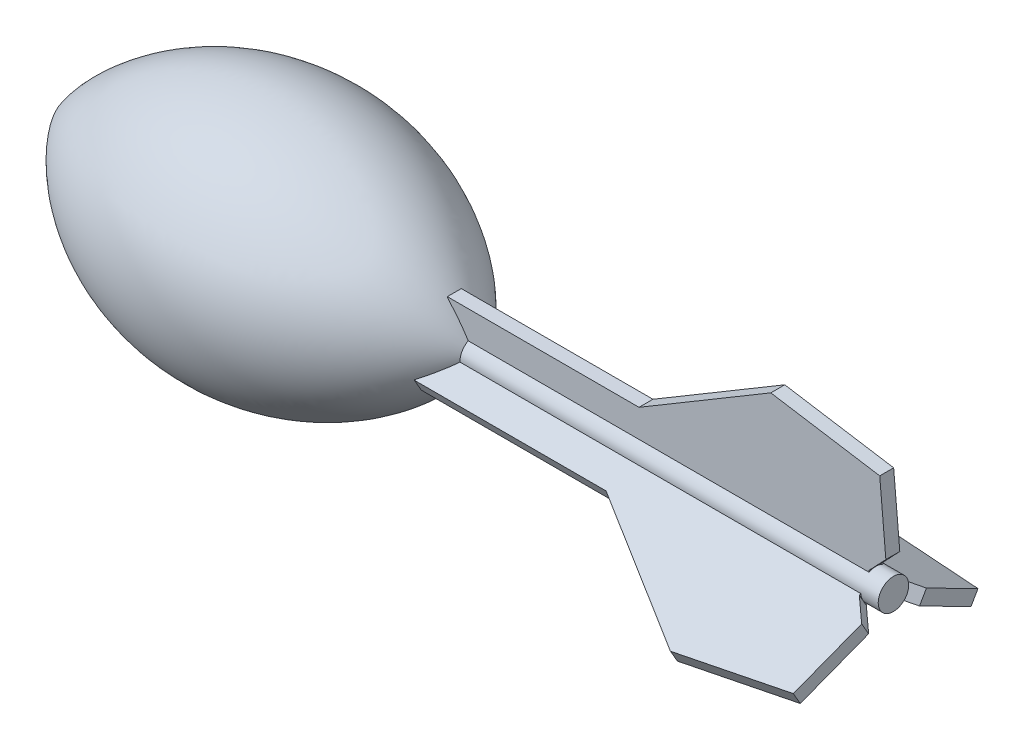
from build123d import *

# Parameters (mm, degrees)
BOSS_EXTRUDE1_DEPTH = 2.54
BOSS_EXTRUDE2_DEPTH = 2.54
BOSS_EXTRUDE3_DEPTH = 2.54


with BuildPart() as part:
    # Sketch1 → Revolve1 (revolve)
    with BuildSketch(Plane(origin=(0, 0, 0), x_dir=(1, 0, 0), z_dir=(0, 1, 0))):
        with BuildLine():
            Line((152.4, 0), (152.4, 5.55625))
            Line((152.4, 5.55625), (0, 5.55625))
            ThreePointArc((0, 5.55625), (-77.717093166, 44.389823275), (-152.4, 0))
            Line((-152.4, 0), (0, 0))
            Line((0, 0), (152.4, 0))
        make_face()
    revolve(axis=Axis((-152.4, 0, 0), (1, 0, 0)))



with BuildPart() as body_2:
    # Sketch2 → Boss-Extrude1 (new, symmetric)
    with BuildSketch(Plane.XY):
        Polygon((146.05, 0), (146.05, 5.55625), (152.169647951, 12.004661351), (149.935904042, 37.30625), (110.248404042, 43.65625), (62.227119438, 15.08125), (-7.622880562, 15.08125), (-7.622880562, 0), align=None)
    extrude(amount=BOSS_EXTRUDE1_DEPTH, both=True)


with BuildPart() as part_1:
    add(part.part)

    add(body_2.part)  # Boss-Extrude2 merges body 2
    # Sketch4 → Boss-Extrude2 (add, symmetric)
    with BuildSketch(Plane(origin=(0, 0, 0), x_dir=(-1, 0, 0), z_dir=(0, 0.8660254037844434, 0.49999999999999206))):
        Polygon((7.739597156, 0), (7.739597156, 15.20825), (-62.110402844, 15.20825), (-110.207031583, 43.65625), (-149.277729937, 37.057620888), (-152.336179285, 11.842429285), (-146.05, 5.55625), (-146.05, 0), align=None)
    extrude(amount=BOSS_EXTRUDE2_DEPTH, both=True)

    # Sketch7 → Boss-Extrude3 (add, symmetric)
    with BuildSketch(Plane(origin=(0, 0, 0), x_dir=(-1, 0, 0), z_dir=(0, -0.8660254037844364, 0.5000000000000041))):
        Polygon((7.333629766, 0.03041902), (7.333629766, 15.392738785), (-62.516370234, 15.392738785), (-110.612998972, 43.840738785), (-149.683697326, 37.242109673), (-152.742146674, 12.02691807), (-146.455967389, 5.740738785), (-146.455967389, 0.03041902), align=None)
    extrude(amount=BOSS_EXTRUDE3_DEPTH, both=True)


solid = part_1.part
